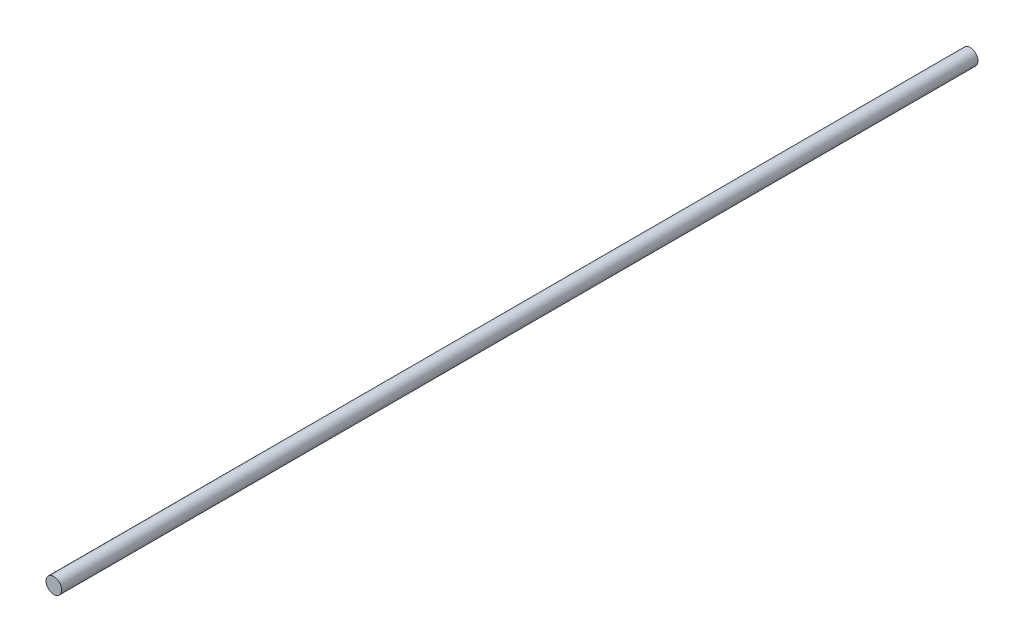
from build123d import *

# Parameters (mm, degrees)
SKETCH_1_R      = 1.45
EXTRUDE_1_DEPTH = 170


with BuildPart() as part:
    # 草图1 → 凸台-拉伸1 (new body)
    with BuildSketch(Plane.XY):
        with Locations((-1.384615385, 4.528846154)):
            Circle(SKETCH_1_R)
    extrude(amount=EXTRUDE_1_DEPTH)


solid = part.part
